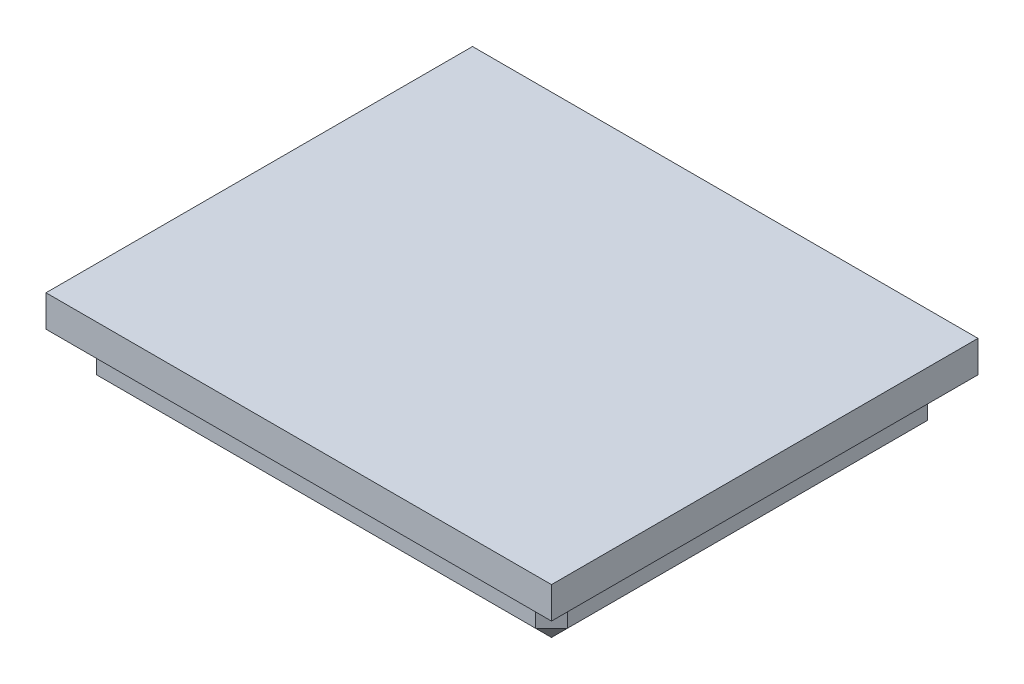
from build123d import *

# Parameters (mm, degrees)
SKETCH1_W           = 29.8
SKETCH1_H           = 24.8
BOSS_EXTRUDE1_DEPTH = 3
SKETCH2_W           = 32
SKETCH2_H           = 27
BOSS_EXTRUDE2_DEPTH = 2
CHAMFER1_SIZE       = 1


with BuildPart() as part:
    # Sketch1 → Boss-Extrude1 (new body)
    with BuildSketch(Plane(origin=(0, 0, 0), x_dir=(1, 0, 0), z_dir=(0, 1, 0))):
        Rectangle(SKETCH1_W, SKETCH1_H)
    extrude(amount=BOSS_EXTRUDE1_DEPTH)

    # Sketch2 → Boss-Extrude2 (add)
    with BuildSketch(Plane(origin=(0, 3, 0), x_dir=(1, 0, 0), z_dir=(0, 1, 0))):
        Rectangle(SKETCH2_W, SKETCH2_H)
    extrude(amount=BOSS_EXTRUDE2_DEPTH)

    # Chamfer1
    chamfer1_edges = [part.edges().sort_by_distance(p)[0] for p in [
        (0, 0, -12.4),
        (14.9, 0, 0),
        (0, 0, 12.4),
        (-14.9, 0, 0),
        (-14.9, 1.5, -12.4),
        (14.9, 1.5, -12.4),
        (14.9, 1.5, 12.4),
        (-14.9, 1.5, 12.4),
    ]]
    chamfer(chamfer1_edges, length=CHAMFER1_SIZE)


solid = part.part
